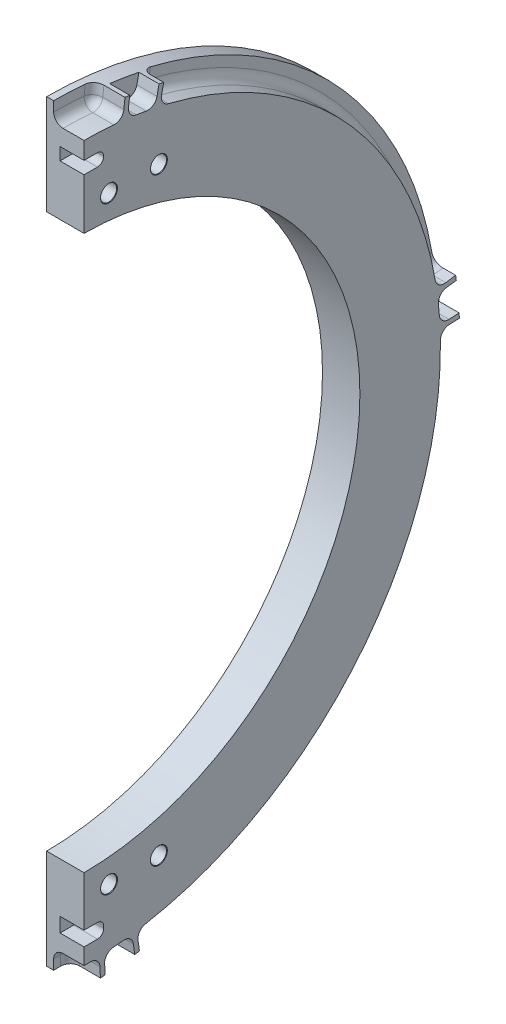
from build123d import *

# Parameters (mm, degrees)
SKETCH1_W                         = 19.05
SKETCH1_H                         = 50.8
REVOLVE_THIN1_ANGLE               = 180
SKETCH81_W                        = 0.5
SKETCH81_H                        = 430
EXTRUDE1_DEPTH                    = 20.05
F_5_16_CLEARANCE_HOLE1_AT_2_COUNT = 2
F_5_16_CLEARANCE_HOLE1_AT_2_PITCH = 25.4
F_5_16_CLEARANCE_HOLE1_AT_3_COUNT = 2
F_5_16_CLEARANCE_HOLE1_AT_3_PITCH = 304.8
F_5_16_CLEARANCE_HOLE1_AT_4_COUNT = 2
F_5_16_CLEARANCE_HOLE1_AT_4_PITCH = 305.856502301
CUT_EXTRUDE1_DEPTH                = 11.311296
CUT_EXTRUDE2_DEPTH                = 4.175
BOSS_EXTRUDE1_DEPTH               = 1.064737
FILLET1_R                         = 4.7625
FILLET2_R                         = 4.7625
SKETCH90_W                        = 10
SKETCH90_H                        = 6.35254
CUT_EXTRUDE3_DEPTH                = 12.24534
SKETCH91_W                        = 10
SKETCH91_H                        = 7.35254
CUT_EXTRUDE4_DEPTH                = 12.24534
FILLET3_R                         = 3.175


with BuildPart() as part:
    # Sketch1 → Revolve-Thin1 (revolve)
    with BuildSketch(Plane.XY):
        with Locations((9.525, 166.3625)):
            Rectangle(SKETCH1_W, SKETCH1_H)
    revolve(axis=Axis((0, 0, 0), (-1, 0, 0)), revolution_arc=REVOLVE_THIN1_ANGLE)

    # Sketch81 → Extrude1 (cut, through all)
    with BuildSketch(Plane(origin=(0, 0, 0), x_dir=(0, 0, -1), z_dir=(1, 0, 0))):
        with Locations((0.25, 0)):
            Rectangle(SKETCH81_W, SKETCH81_H)
    extrude(amount=EXTRUDE1_DEPTH, mode=Mode.SUBTRACT)

    # Sketch83 → 5_16 Clearance Hole1 (revolve, cut)
    with BuildSketch(Plane(origin=(19.05, 152.4, -38.6), x_dir=(0, 0, -1), z_dir=(0, 1, 0))):
        Polygon((0, 0), (0, 19.05), (4.318, 19.05), (4.1021, 18.8341), (4.1021, 0.2159), (4.318, 0), align=None)
    f_5_16_clearance_hole1 = revolve(axis=Axis((25.4, 152.4, -38.6), (-1, 0, 0)), mode=Mode.SUBTRACT)

    # 5_16 Clearance Hole1 at 2: 5_16 Clearance Hole1 ×2
    with Locations(*[(0, 0, i * F_5_16_CLEARANCE_HOLE1_AT_2_PITCH) for i in range(1, F_5_16_CLEARANCE_HOLE1_AT_2_COUNT)]):
        add(f_5_16_clearance_hole1, mode=Mode.SUBTRACT)

    # 5_16 Clearance Hole1 at 3: 5_16 Clearance Hole1 ×2
    with Locations(*[(0, -i * F_5_16_CLEARANCE_HOLE1_AT_3_PITCH, 0) for i in range(1, F_5_16_CLEARANCE_HOLE1_AT_3_COUNT)]):
        add(f_5_16_clearance_hole1, mode=Mode.SUBTRACT)

    # 5_16 Clearance Hole1 at 4: 5_16 Clearance Hole1 ×2
    with Locations(*[Vector(0, -0.996545758, 0.08304548) * (i * F_5_16_CLEARANCE_HOLE1_AT_4_PITCH) for i in range(1, F_5_16_CLEARANCE_HOLE1_AT_4_COUNT)]):
        add(f_5_16_clearance_hole1, mode=Mode.SUBTRACT)

    # Sketch87 → Cut-Extrude1 (cut)
    with BuildSketch(Plane(origin=(19.05, 0, 0), x_dir=(0, 0, -1), z_dir=(1, 0, 0))):
        with BuildLine():
            Line((0.5, -181.961813044), (0.5, -191.761848151))
            ThreePointArc((0.5, -191.761848151), (4.660403781, -191.705860742), (8.818613515, -191.559621168))
            Line((8.818613515, -191.559621168), (8.367939309, -181.769989267))
            ThreePointArc((8.367939309, -181.769989267), (4.435006876, -181.908444335), (0.5, -181.961813044))
        make_face()
        with BuildLine():
            Line((0.5, 181.961813044), (0.5, 191.761848151))
            ThreePointArc((0.5, 191.761848151), (10.930348477, 191.450734886), (21.328330845, 190.572712395))
            Line((21.328330845, 190.572712395), (20.238349007, 180.833516351))
            ThreePointArc((20.238349007, 180.833516351), (10.384509774, 181.665938918), (0.5, 181.961813044))
        make_face()
        with BuildLine():
            Line((10.691988388, -181.648101533), (11.267829489, -191.431168896))
            ThreePointArc((11.267829489, -191.431168896), (18.796011872, -190.839111148), (26.295047079, -189.951117147))
            Line((26.295047079, -189.951117147), (24.951241792, -180.243687654))
            ThreePointArc((24.951241792, -180.243687654), (17.835443897, -181.086300827), (10.691988388, -181.648101533))
        make_face()
        with BuildLine():
            Line((27.254414037, -179.909833866), (28.72226185, -189.599282911))
            ThreePointArc((28.72226185, -189.599282911), (147.968659172, -121.975949716), (191.596275996, 7.982695695))
            Line((191.596275996, 7.982695695), (181.804770855, 7.574740971))
            ThreePointArc((181.804770855, 7.574740971), (140.406738255, -115.742383157), (27.254414037, -179.909833866))
        make_face()
        with BuildLine():
            Line((180.027040692, 26.469152346), (189.722802175, 27.894708123))
            ThreePointArc((189.722802175, 27.894708123), (140.246214207, 130.781710521), (41.061151684, 187.314810489))
            Line((41.061151684, 187.314810489), (38.962726359, 177.742109138))
            ThreePointArc((38.962726359, 177.742109138), (133.078947931, 124.098126593), (180.027040692, 26.469152346))
        make_face()
        with BuildLine():
            Line((22.54945028, 180.559889506), (23.763901679, 190.284348761))
            ThreePointArc((23.763901679, 190.284348761), (31.237243217, 189.201191969), (38.662144827, 187.824638862))
            Line((38.662144827, 187.824638862), (36.686320465, 178.225882792))
            ThreePointArc((36.686320465, 178.225882792), (29.640867578, 179.532087314), (22.54945028, 180.559889506))
        make_face()
        with BuildLine():
            Line((181.693024826, 9.89929976), (191.478511634, 10.43244883))
            ThreePointArc((191.478511634, 10.43244883), (190.919307311, 17.963142882), (190.064042372, 25.465981296))
            Line((190.064042372, 25.465981296), (180.350841849, 24.164545318))
            ThreePointArc((180.350841849, 24.164545318), (181.162398574, 17.045138579), (181.693024826, 9.89929976))
        make_face()
    extrude(amount=-CUT_EXTRUDE1_DEPTH, mode=Mode.SUBTRACT)

    # Sketch88 → Cut-Extrude2 (cut)
    with BuildSketch(Plane(origin=(7.738704, 0, 0), x_dir=(0, 0, -1), z_dir=(1, 0, 0))):
        with BuildLine():
            Line((8.818613515, -191.559621168), (8.367939309, -181.769989267))
            ThreePointArc((8.367939309, -181.769989267), (4.435006876, -181.908444335), (0.5, -181.961813044))
            Line((0.5, -181.961813044), (0.5, -191.761848151))
            ThreePointArc((0.5, -191.761848151), (4.660403781, -191.705860742), (8.818613515, -191.559621168))
        make_face()
        with BuildLine():
            Line((0.5, 191.761848151), (0.5, 181.961813044))
            ThreePointArc((0.5, 181.961813044), (10.384509774, 181.665938918), (20.238349007, 180.833516351))
            Line((20.238349007, 180.833516351), (21.328330845, 190.572712395))
            ThreePointArc((21.328330845, 190.572712395), (10.930348477, 191.450734886), (0.5, 191.761848151))
        make_face()
    extrude(amount=-CUT_EXTRUDE2_DEPTH, mode=Mode.SUBTRACT)

    # Sketch89 → Boss-Extrude1 (add)
    with BuildSketch(Plane(origin=(7.738704, 0, 0), x_dir=(0, 0, -1), z_dir=(1, 0, 0))):
        with BuildLine():
            Line((23.763901679, 190.284348761), (22.54945028, 180.559889506))
            ThreePointArc((22.54945028, 180.559889506), (29.640867578, 179.532087314), (36.686320465, 178.225882792))
            Line((36.686320465, 178.225882792), (38.662144827, 187.824638862))
            ThreePointArc((38.662144827, 187.824638862), (31.237243217, 189.201191969), (23.763901679, 190.284348761))
        make_face()
        with BuildLine():
            Line((190.064042372, 25.465981296), (180.350841849, 24.164545318))
            ThreePointArc((180.350841849, 24.164545318), (181.162398574, 17.045138579), (181.693024826, 9.89929976))
            Line((181.693024826, 9.89929976), (191.478511634, 10.43244883))
            ThreePointArc((191.478511634, 10.43244883), (190.919307311, 17.963142882), (190.064042372, 25.465981296))
        make_face()
        with BuildLine():
            Line((26.295047079, -189.951117147), (24.951241792, -180.243687654))
            ThreePointArc((24.951241792, -180.243687654), (17.835443897, -181.086300827), (10.691988388, -181.648101533))
            Line((10.691988388, -181.648101533), (11.267829489, -191.431168896))
            ThreePointArc((11.267829489, -191.431168896), (18.796011872, -190.839111148), (26.295047079, -189.951117147))
        make_face()
    extrude(amount=BOSS_EXTRUDE1_DEPTH)

    # Fillet1
    fillet1_edges = [part.edges().sort_by_distance(p)[0] for p in [
        (11.306852, -181.769989267, -8.367939309),
        (11.306852, 180.833516351, -20.238349007),
        (13.394352, -179.909833866, -27.254414037),
        (13.394352, 7.574740971, -181.804770855),
        (13.394352, 26.469152346, -180.027040692),
        (13.394352, 177.742109138, -38.962726359),
        (13.9267205, 180.559889506, -22.54945028),
        (13.9267205, 178.225882792, -36.686320465),
        (13.9267205, 24.164545318, -180.350841849),
        (13.9267205, 9.89929976, -181.693024826),
        (13.9267205, -180.243687654, -24.951241792),
        (13.9267205, -181.648101533, -10.691988388),
    ]]
    fillet(fillet1_edges, radius=FILLET1_R)

    # Fillet2
    fillet2_edges = [part.edges().sort_by_distance(p)[0] for p in [
        (7.738704, 7.876580746, -189.049363299),
        (7.738704, 184.824811835, -40.51532078),
        (3.563704, -189.013195727, -8.701386609),
        (3.563704, 181.783605025, -8.066743481),
        (3.563704, 188.039406053, -21.044810738),
        (3.563704, 182.35275146, -19.047706642),
        (7.738704, 124.098126593, -133.078947931),
        (7.738704, 27.523900361, -187.200793793),
        (7.738704, 28.007358428, -181.193070969),
        (7.738704, 178.797999192, -40.578523608),
        (3.563704, -181.950212254, -2.114631617),
        (3.563704, -183.20809984, -7.080483471),
        (7.738704, -187.078916486, -28.340453315),
        (7.738704, -115.742383157, -140.406738255),
        (7.738704, 6.281022467, -183.237250171),
        (7.738704, -181.069141374, -28.797693227),
    ]]
    fillet(fillet2_edges, radius=FILLET2_R)

    # Sketch90 → Cut-Extrude3 (cut)
    with BuildSketch(Plane(origin=(19.05, 0, 0), x_dir=(0, 0, -1), z_dir=(1, 0, 0))):
        with Locations((5.5, 170)):
            Rectangle(SKETCH90_W, SKETCH90_H)
        with Locations((5.5, -170)):
            Rectangle(SKETCH90_W, SKETCH90_H)
    extrude(amount=-CUT_EXTRUDE3_DEPTH, mode=Mode.SUBTRACT)

    # Sketch91 → Cut-Extrude4 (cut)
    with BuildSketch(Plane(origin=(19.05, 0, 0), x_dir=(0, 0, -1), z_dir=(1, 0, 0))):
        with Locations((5.5, -170)):
            Rectangle(SKETCH91_W, SKETCH91_H)
    extrude(amount=-CUT_EXTRUDE4_DEPTH, mode=Mode.SUBTRACT)

    # Fillet3
    fillet3_edges = [part.edges().sort_by_distance(p)[0] for p in [
        (12.92733, 173.17627, -10.5),
        (12.92733, 166.82373, -10.5),
        (12.92733, -166.32373, -10.5),
        (12.92733, -173.67627, -10.5),
    ]]
    fillet(fillet3_edges, radius=FILLET3_R)


solid = part.part
